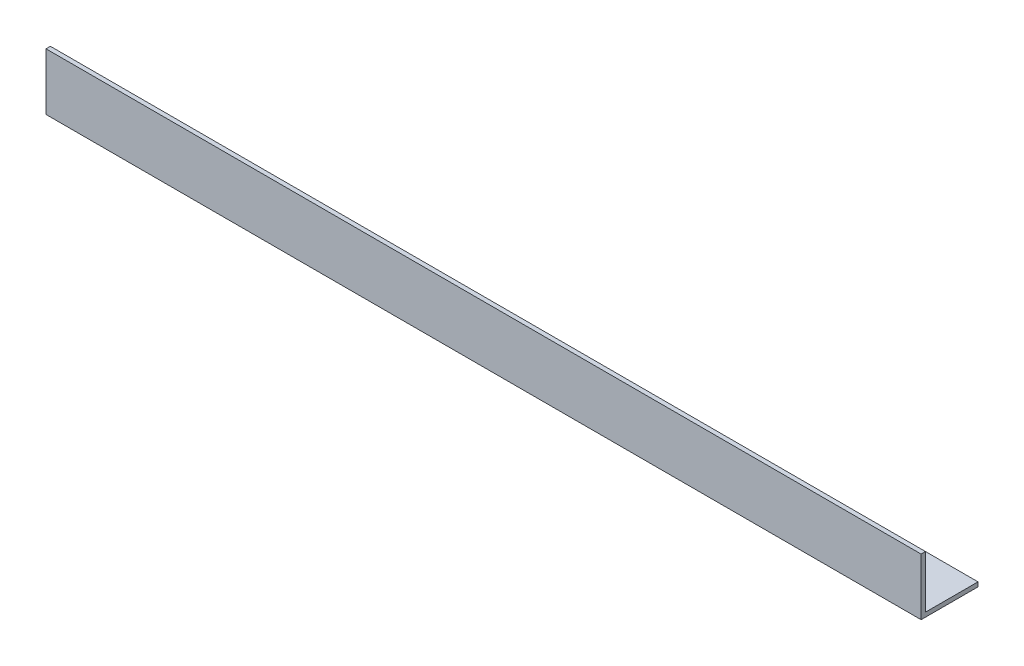
from build123d import *

# Parameters (mm, degrees)
EXTRUDE_1_DEPTH = 1000


with BuildPart() as part:
    # Эскиз1 → Вытянуть-Тонкостенный1 (new body)
    with BuildSketch(Plane(origin=(0, 0, 0), x_dir=(0, 0, -1), z_dir=(1, 0, 0))):
        Polygon((65, 0), (0, 0), (0, 65), (5, 65), (5, 5), (65, 5), align=None)
    extrude(amount=EXTRUDE_1_DEPTH)


solid = part.part
